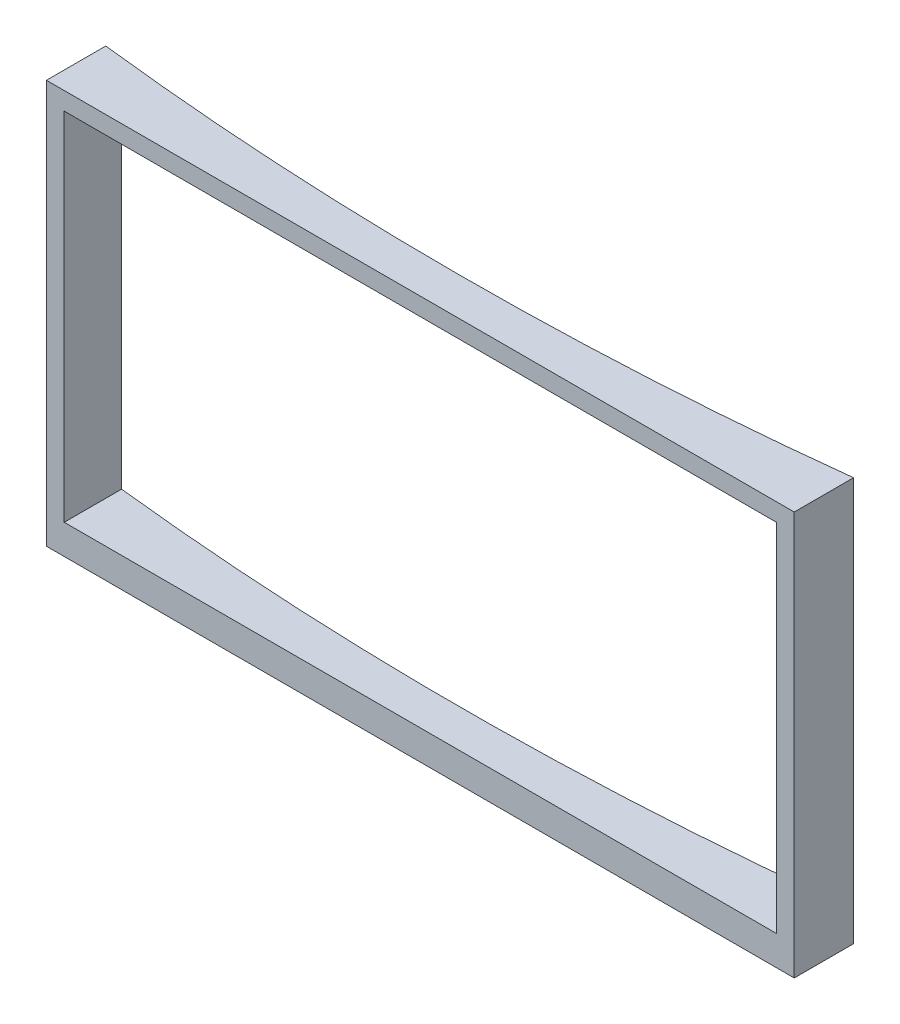
from build123d import *

# Parameters (mm, degrees)
BOSS_EXTRUDE1_DEPTH = 3550
SKETCH3_W           = 6000
SKETCH3_H           = 3000
CUT_EXTRUDE1_DEPTH  = 6000
SKETCH4_W           = 6300
SKETCH4_H           = 155.176049704
CUT_EXTRUDE2_DEPTH  = 1116


with BuildPart() as part:
    # Sketch2 → Boss-Extrude1 (new body)
    with BuildSketch(Plane(origin=(0, 0, 0), x_dir=(1, 0, 0), z_dir=(0, 1, 0))):
        with BuildLine():
            Line((2590.546480495, -3013.609856922), (8890.546480495, -3013.609856922))
            Line((8890.546480495, -3013.609856922), (8890.546480495, -2513.609856922))
            ThreePointArc((8890.546480495, -2513.609856922), (5740.546480495, -2694.614633818), (2590.546480495, -2513.609856922))
            Line((2590.546480495, -2513.609856922), (2590.546480495, -3013.609856922))
        make_face()
    extrude(amount=BOSS_EXTRUDE1_DEPTH)

    # Sketch3 → Cut-Extrude1 (cut)
    with BuildSketch(Plane.XY.offset(3013.609856922)):
        with Locations((5740.546480495, 1750)):
            Rectangle(SKETCH3_W, SKETCH3_H)
    extrude(amount=-CUT_EXTRUDE1_DEPTH, mode=Mode.SUBTRACT)

    # Sketch4 → Cut-Extrude2 (cut)
    with BuildSketch(Plane.XY.offset(3013.609856922)):
        with Locations((5740.546480495, 3477.588024852)):
            Rectangle(SKETCH4_W, SKETCH4_H)
    extrude(amount=-CUT_EXTRUDE2_DEPTH, mode=Mode.SUBTRACT)


solid = part.part
